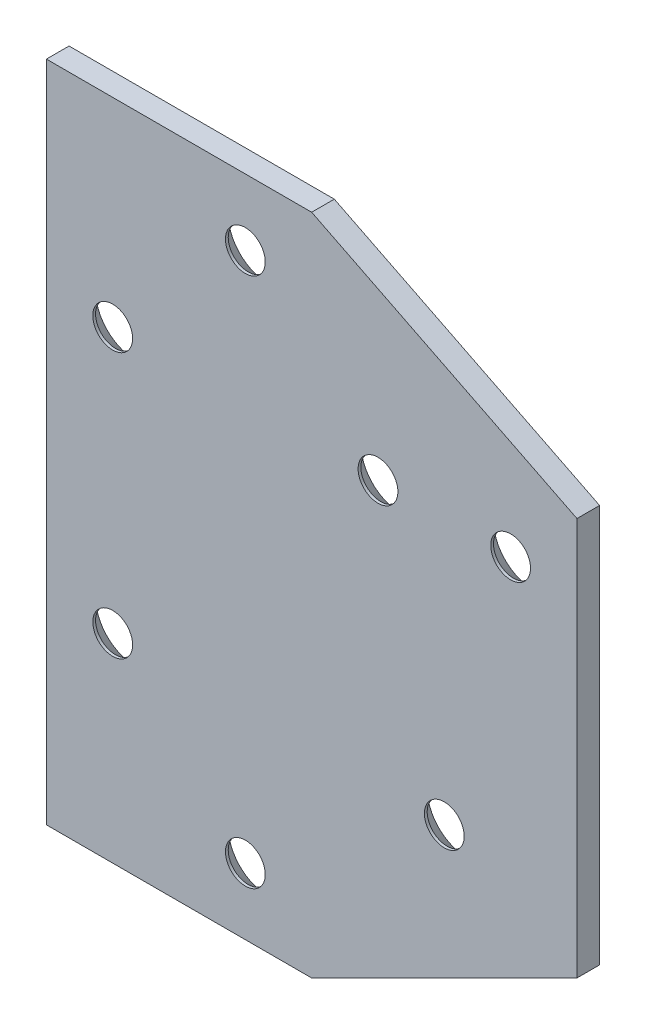
from build123d import *

# Parameters (mm, degrees)
BOSS_EXTRUDE1_DEPTH = 3.416
SKETCH2_R           = 3
CUT_EXTRUDE1_DEPTH  = 4.416
CHAMFER1_SIZE       = 3


with BuildPart() as part:
    # Sketch1 → Boss-Extrude1 (new body)
    with BuildSketch(Plane.XY):
        Polygon((-20, -50), (20, -50), (60, -30), (60, 30), (20, 50), (-20, 50), align=None)
    extrude(amount=BOSS_EXTRUDE1_DEPTH)

    # Sketch2 → Cut-Extrude1 (cut, through all)
    with BuildSketch(Plane.XY.offset(3.416)):
        with Locations((-10, 20)):
            Circle(SKETCH2_R)
        with Locations((10, 40)):
            Circle(SKETCH2_R)
        with Locations((30, 20)):
            Circle(SKETCH2_R)
        with Locations((50, 20)):
            Circle(SKETCH2_R)
        with Locations((-10, -20)):
            Circle(SKETCH2_R)
        with Locations((10, -40)):
            Circle(SKETCH2_R)
        with Locations((40, -20)):
            Circle(SKETCH2_R)
    extrude(amount=-CUT_EXTRUDE1_DEPTH, mode=Mode.SUBTRACT)

    # Chamfer1
    chamfer1_edges = [part.edges().sort_by_distance(p)[0] for p in [
        (-13, -20, 0),
        (47, 20, 0),
        (27, 20, 0),
        (7, 40, 0),
        (7, -40, 0),
        (37, -20, 0),
        (-13, 20, 0),
    ]]
    chamfer(chamfer1_edges, length=CHAMFER1_SIZE)


solid = part.part
